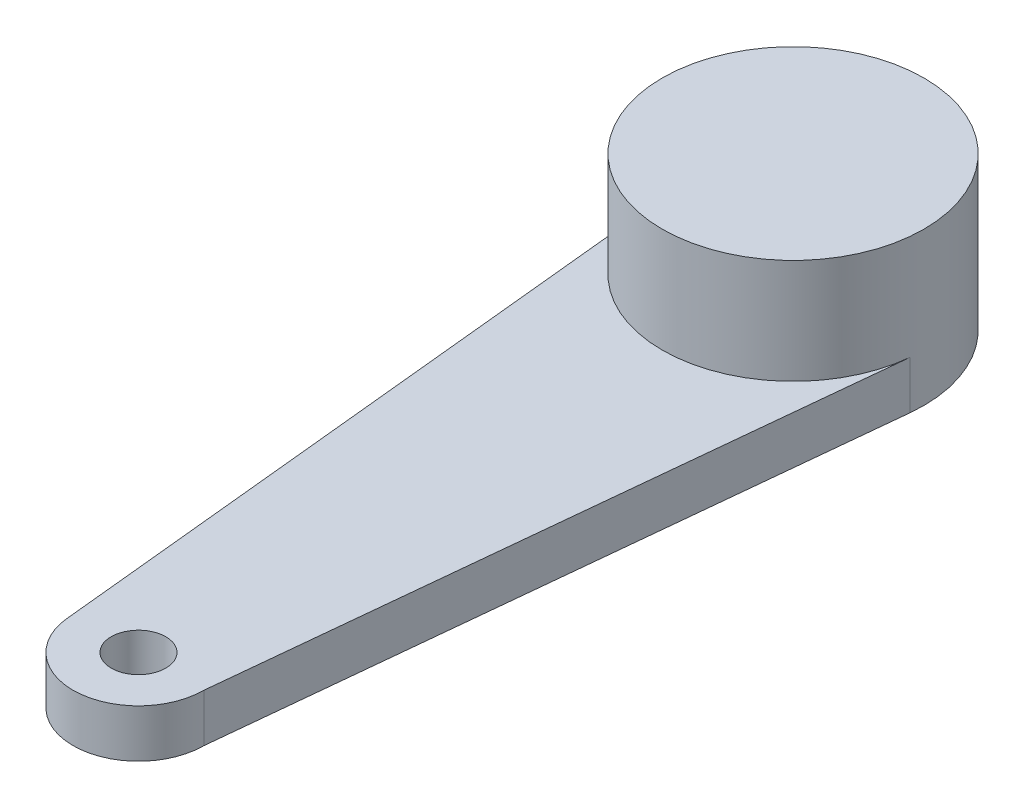
from build123d import *

# Parameters (mm, degrees)
SKETCH1_R           = 3
BOSS_EXTRUDE1_DEPTH = 3.5
SKETCH2_R           = 1.5
SKETCH2_R_2         = 0.625
BOSS_EXTRUDE2_DEPTH = 1.1


with BuildPart() as part:
    # Sketch1 → Boss-Extrude1 (new body)
    with BuildSketch(Plane(origin=(0, 0, 0), x_dir=(1, 0, 0), z_dir=(0, 1, 0))):
        Circle(SKETCH1_R)
    extrude(amount=BOSS_EXTRUDE1_DEPTH)

    # Sketch2 → Boss-Extrude2 (add)
    with BuildSketch(Plane(origin=(0, 0, 0), x_dir=(1, 0, 0), z_dir=(0, 1, 0))):
        with Locations((0, -15)):
            Circle(SKETCH2_R)
        with Locations((0, -15)):
            Circle(SKETCH2_R_2, mode=Mode.SUBTRACT)
        with BuildLine():
            ThreePointArc((2.984809248, -0.301519075), (-0.000763384, -2.999999903), (-2.984962311, -0.3))
            Line((-2.984962311, -0.3), (-1.492481156, -15.15))
            ThreePointArc((-1.492481156, -15.15), (-0.075094163, -13.50188089), (1.5, -15))
            Line((1.5, -15), (2.984809248, -0.301519075))
        make_face()
    extrude(amount=BOSS_EXTRUDE2_DEPTH)


solid = part.part
